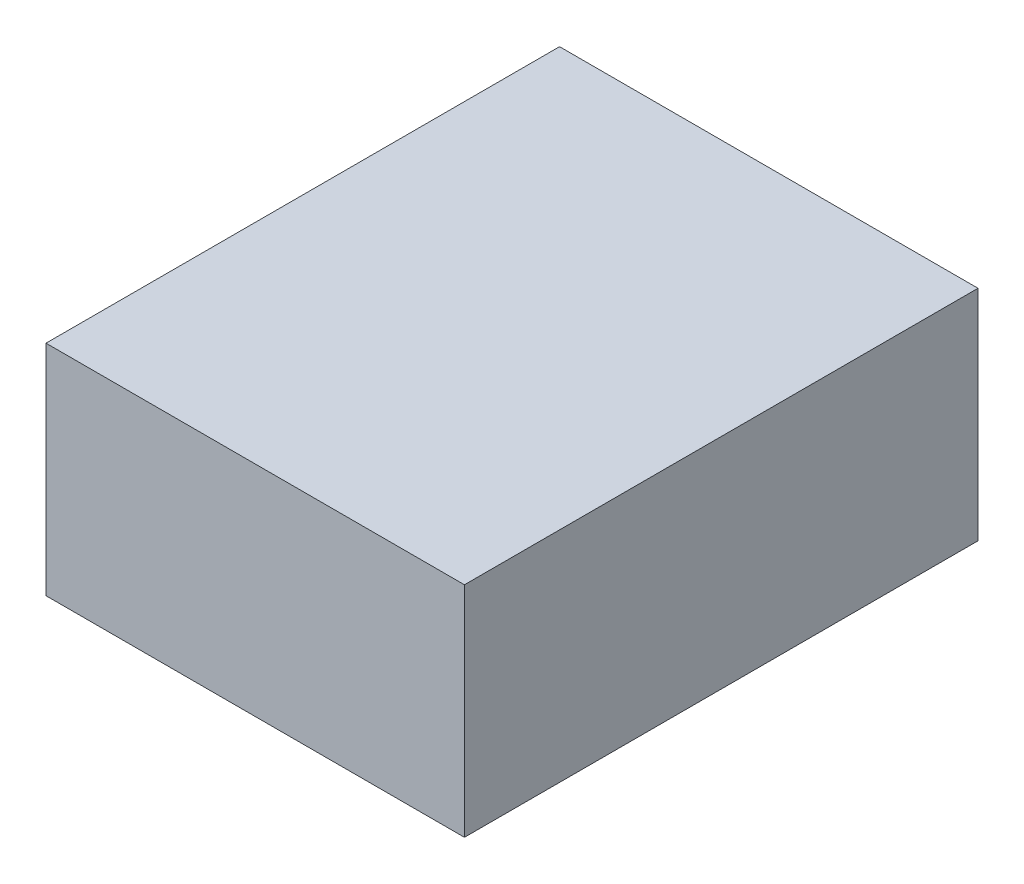
from build123d import *

# Parameters (mm, degrees)
SKETCH_1_W      = 22
SKETCH_1_H      = 11.5
EXTRUDE_1_DEPTH = 27


with BuildPart() as part:
    # ｽｹｯﾁ1 → ﾎﾞｽ - 押し出し1 (new body)
    with BuildSketch(Plane.XY):
        with Locations((-29.059413826, 14.79109589)):
            Rectangle(SKETCH_1_W, SKETCH_1_H)
    extrude(amount=EXTRUDE_1_DEPTH)


solid = part.part
